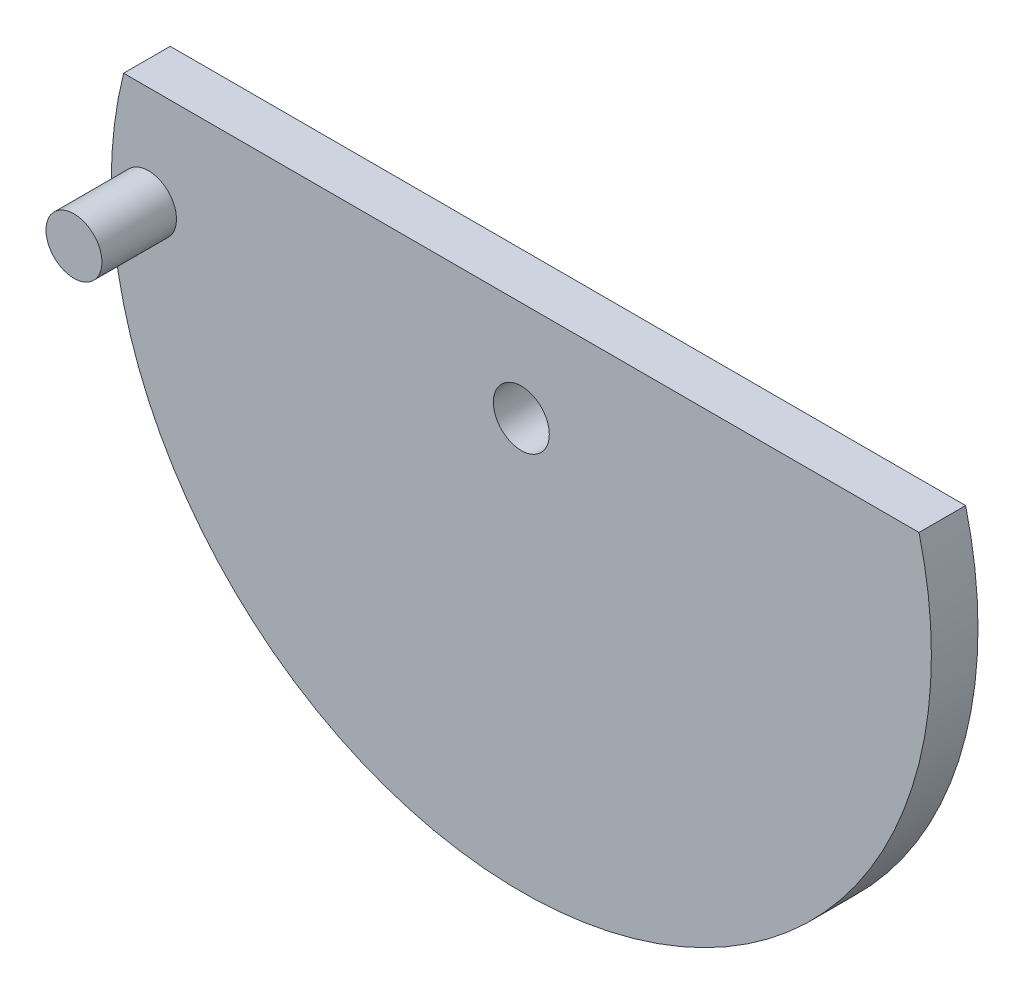
from build123d import *

# Parameters (mm, degrees)
SKETCH1_R           = 1.5
BOSS_EXTRUDE1_DEPTH = 2.5
SKETCH2_R           = 1.5
BOSS_EXTRUDE2_DEPTH = 4


with BuildPart() as part:
    # Sketch1 → Boss-Extrude1 (new body)
    with BuildSketch(Plane.XY):
        with BuildLine():
            Line((-21.335922229, 13.682276209), (21.335922229, 13.682276209))
            ThreePointArc((21.335922229, 13.682276209), (0, -13.682276209), (-21.335922229, 13.682276209))
        make_face()
        with Locations((0, 8.317723791)):
            Circle(SKETCH1_R, mode=Mode.SUBTRACT)
    extrude(amount=BOSS_EXTRUDE1_DEPTH)

    # Sketch2 → Boss-Extrude2 (add)
    with BuildSketch(Plane.XY.offset(2.5)):
        with Locations((-20, 8.317723791)):
            Circle(SKETCH2_R)
    extrude(amount=BOSS_EXTRUDE2_DEPTH)


solid = part.part
